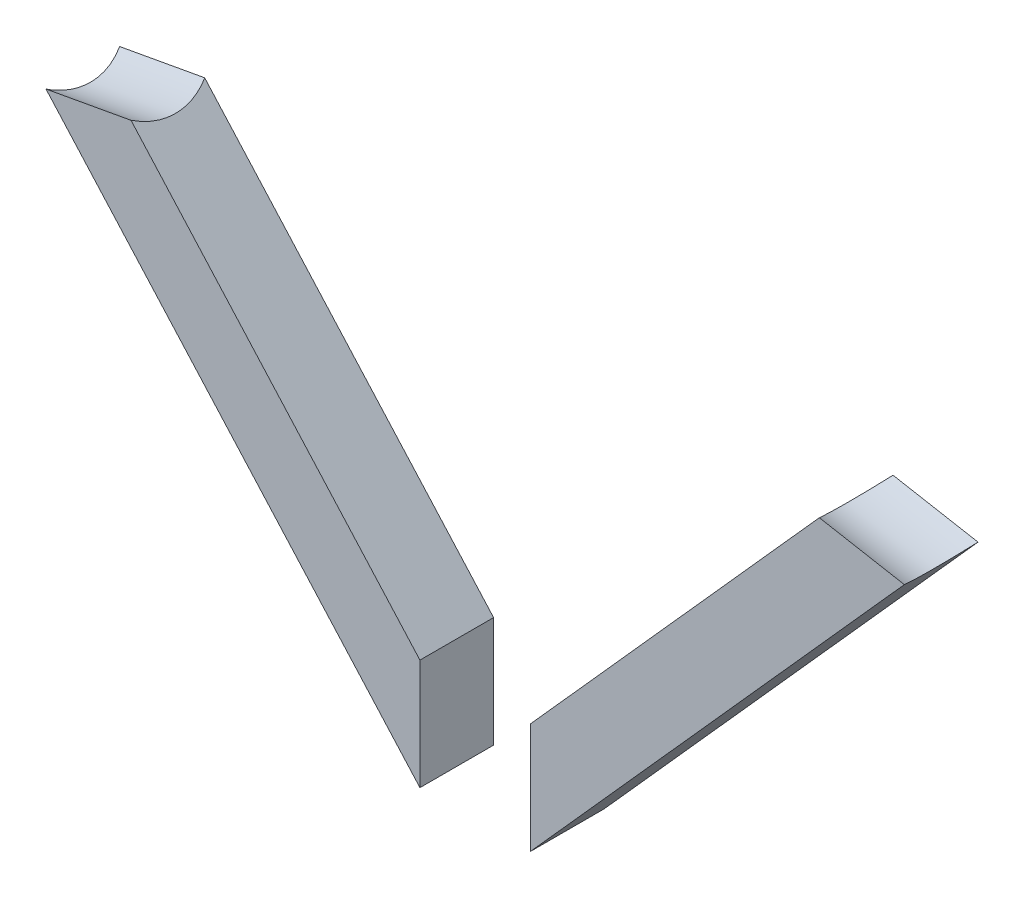
from build123d import *

# Parameters (mm, degrees)
BOSS_EXTRUDE1_DEPTH      = 6.35
BOSS_EXTRUDE1_DEPTH_BACK = 6.35
CUT_EXTRUDE2_DEPTH       = 50.8
CUT_EXTRUDE2_DEPTH_BACK  = 50.8
SKETCH7_R                = 12.7


with BuildPart() as part:
    # Sketch1 → Boss-Extrude1 (new, two sides: drawn at the far end of the back side and taken through both)
    with BuildSketch(Plane.XY.offset(-BOSS_EXTRUDE1_DEPTH_BACK)):
        Polygon((-91.935614725, -38.746248277), (-91.935614725, -19.696248277), (-140.420626518, 34.511642852), (-161.42071071, 57.990450746), (-176.077722952, 55.327488605), (-155.07763876, 31.848680712), align=None)
    extrude(amount=BOSS_EXTRUDE1_DEPTH + BOSS_EXTRUDE1_DEPTH_BACK)

    # Sketch7 → Cut-Extrude2 (cut, two sides: drawn at the far end of the back side and taken through both)
    with BuildSketch(Plane(origin=(-129.863636853, -23.594300302, 0), x_dir=(0, 0, 1), z_dir=(-0.9838929304749452, -0.17875877981633442, 0)).offset(-CUT_EXTRUDE2_DEPTH_BACK)):
        with Locations((0, 71.757181279)):
            Circle(SKETCH7_R)
    extrude(amount=CUT_EXTRUDE2_DEPTH + CUT_EXTRUDE2_DEPTH_BACK, mode=Mode.SUBTRACT)


with BuildPart() as cut_extrude2_kept_piece:
    # of the separate pieces the step leaves, the one the design keeps (cut_extrude2_pieces_kept)
    add(part.part.solids().sort_by_distance((-91.935614725, -38.746248277, 6.35))[0])


with BuildPart() as body_2:
    # Mirror6: mirrored copy
    add(cut_extrude2_kept_piece.part.mirror(Plane(origin=(-82.410614725, 0, 0), x_dir=(0, 0, 1), z_dir=(1, 0, 0))))


solid = Compound([cut_extrude2_kept_piece.part, body_2.part])
